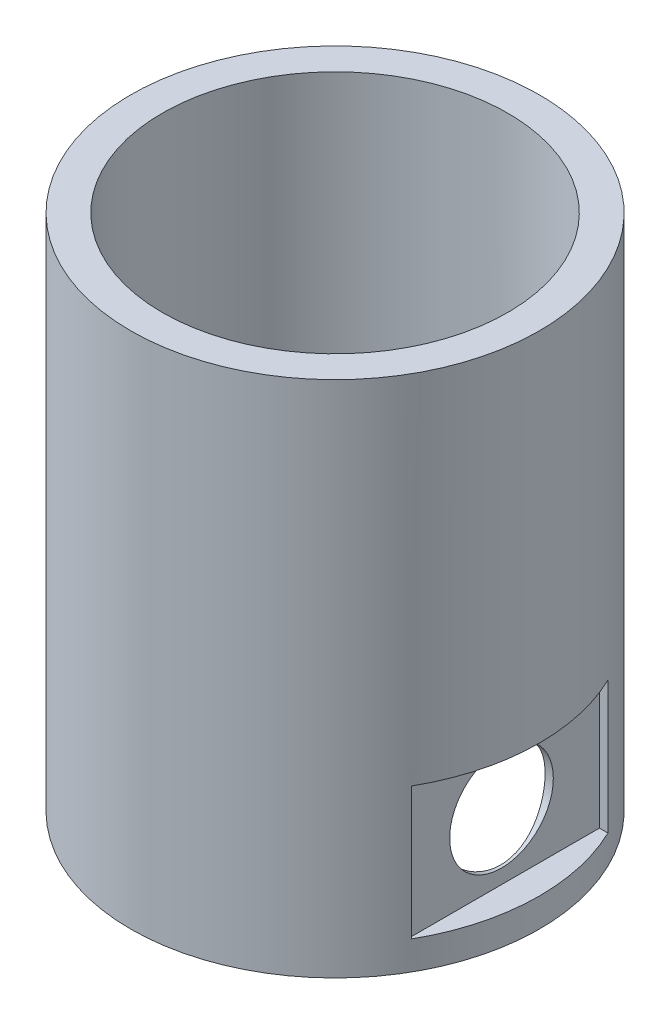
from build123d import *

# Parameters (mm, degrees)
SKETCH1_R               = 17.75
SKETCH1_R_2             = 15
BOSS_EXTRUDE1_DEPTH     = 45
SKETCH2_W               = 16.5
SKETCH2_H               = 11.5
CUT_EXTRUDE1_DEPTH      = 2.5
CUT_EXTRUDE2_REACH      = 60.726
CUT_EXTRUDE2_END_RADIUS = 15
SKETCH3_R               = 4.5
CIRPATTERN1_COUNT       = 2
CIRPATTERN1_ANGLE       = 90


with BuildPart() as part:
    # Sketch1 → Boss-Extrude1 (new body)
    with BuildSketch(Plane(origin=(0, 0, 0), x_dir=(1, 0, 0), z_dir=(0, 1, 0))):
        with Locations(Location((0, 0.545038043, 0), (0, 0, 90))):
            Circle(SKETCH1_R)
        with Locations(Location((0, 0.545038043, 0), (0, 0, 90))):
            Circle(SKETCH1_R_2, mode=Mode.SUBTRACT)
    extrude(amount=BOSS_EXTRUDE1_DEPTH)

    # Sketch2 → Cut-Extrude1 (cut)
    with BuildSketch(Plane(origin=(17.75, 0, 0), x_dir=(0, 0, -1), z_dir=(1, 0, 0))):
        with Locations((0, 8.243102377)):
            Rectangle(SKETCH2_W, SKETCH2_H)
    cut_extrude1 = extrude(amount=-CUT_EXTRUDE1_DEPTH, mode=Mode.SUBTRACT)

    # Cut-Extrude2: up to this cylinder (the profile starts outside it)
    cut_extrude2_end = Plane(origin=(0, 8.243102, -0.545038043), z_dir=(0, -1, 0)) * Cylinder(CUT_EXTRUDE2_END_RADIUS, 152.452, mode=Mode.PRIVATE)
    # Sketch3 → Cut-Extrude2 (cut, up to the surface)
    with BuildSketch(Plane(origin=(15.25, 0, 0), x_dir=(0, 0, -1), z_dir=(1, 0, 0)), mode=Mode.PRIVATE) as cut_extrude2_sk1:
        with Locations((-0.25, 8.243102377)):
            Circle(SKETCH3_R)
    cut_extrude2_tool1 = extrude(cut_extrude2_sk1.sketch, amount=-CUT_EXTRUDE2_REACH, mode=Mode.PRIVATE) - cut_extrude2_end
    cut_extrude2 = cut_extrude2_tool1.solids().sort_by_distance((15.25, 8.243102, 0.25))[0]
    add(cut_extrude2, mode=Mode.SUBTRACT)

    # CirPattern1: Cut-Extrude1, Cut-Extrude2 ×2 about axis
    cirpattern1_axis = Axis((0, 0, -0.545038043), (0, 1, 0))
    add([cut_extrude1.rotate(cirpattern1_axis, i * CIRPATTERN1_ANGLE / (CIRPATTERN1_COUNT - 1)) for i in range(1, CIRPATTERN1_COUNT)], mode=Mode.SUBTRACT)
    add([cut_extrude2.rotate(cirpattern1_axis, i * CIRPATTERN1_ANGLE / (CIRPATTERN1_COUNT - 1)) for i in range(1, CIRPATTERN1_COUNT)], mode=Mode.SUBTRACT)


solid = part.part
